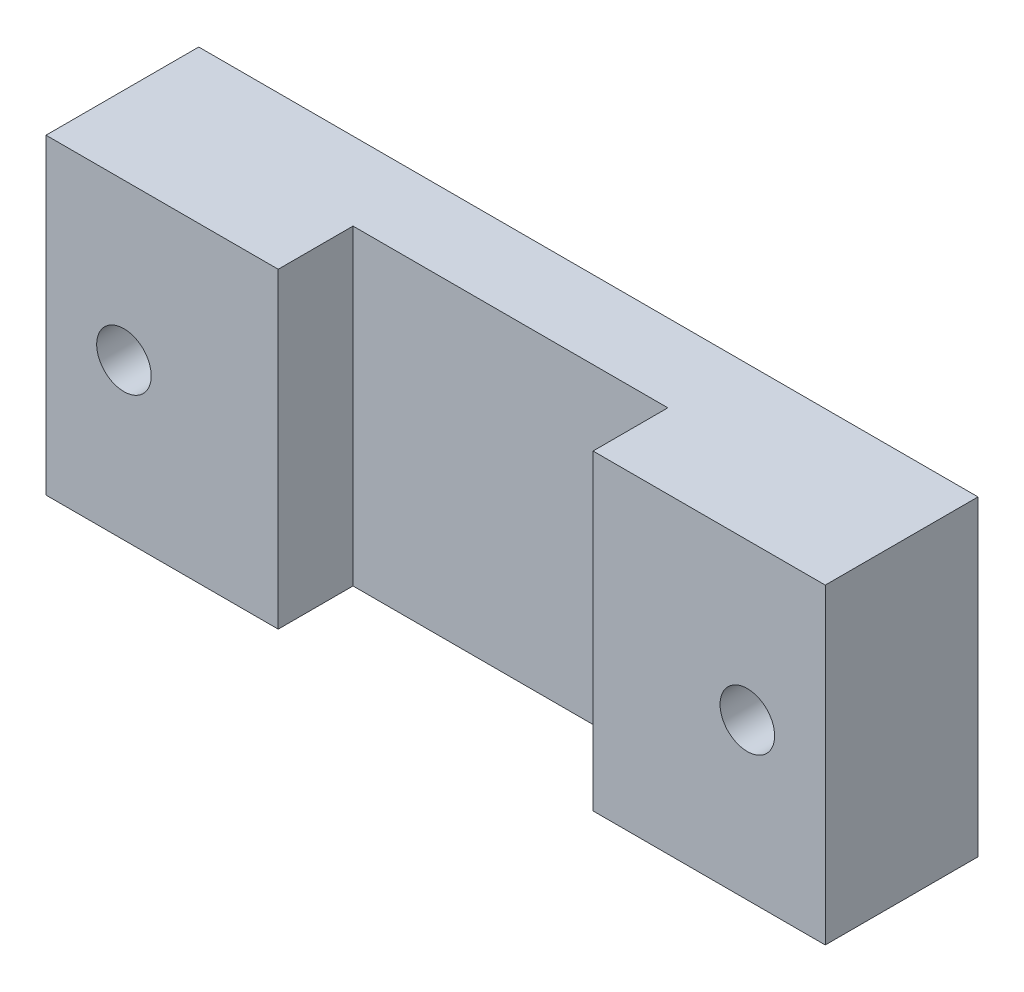
from build123d import *

# Parameters (mm, degrees)
SKETCH2_W           = 50
SKETCH2_H           = 20
SKETCH2_R           = 1.75
BOSS_EXTRUDE1_DEPTH = 5
BOSS_EXTRUDE2_DEPTH = 20
SKETCH6_R           = 1.75
CUT_EXTRUDE1_DEPTH  = 10.8


with BuildPart() as part:
    # Sketch2 → Boss-Extrude1 (new body)
    with BuildSketch(Plane.XY):
        Rectangle(SKETCH2_W, SKETCH2_H)
        with Locations((-20, 0)):
            Circle(SKETCH2_R, mode=Mode.SUBTRACT)
        with Locations((20, 0)):
            Circle(SKETCH2_R, mode=Mode.SUBTRACT)
    extrude(amount=BOSS_EXTRUDE1_DEPTH)

    # Sketch5 → Boss-Extrude2 (add)
    with BuildSketch(Plane.XZ.offset(10)):
        with BuildLine():
            Line((-25, 5), (-25, 9.8))
            Line((-25, 9.8), (-10.1, 9.8))
            Line((-10.1, 9.8), (-10.1, 5))
            Line((-10.1, 5), (10.1, 5))
            Line((10.1, 5), (10.1, 9.8))
            Line((10.1, 9.8), (25, 9.8))
            Line((25, 9.8), (25, 5))
            ThreePointArc((25, 5), (0, 0), (-25, 5))
        make_face()
    extrude(amount=-BOSS_EXTRUDE2_DEPTH)

    # Sketch6 → Cut-Extrude1 (cut, through all)
    with BuildSketch(Plane(origin=(0, 0, 0), x_dir=(-1, 0, 0), z_dir=(0, 0, -1))):
        with Locations((20, 0)):
            Circle(SKETCH6_R)
        with Locations((-20, 0)):
            Circle(SKETCH6_R)
    extrude(amount=-CUT_EXTRUDE1_DEPTH, mode=Mode.SUBTRACT)


solid = part.part
